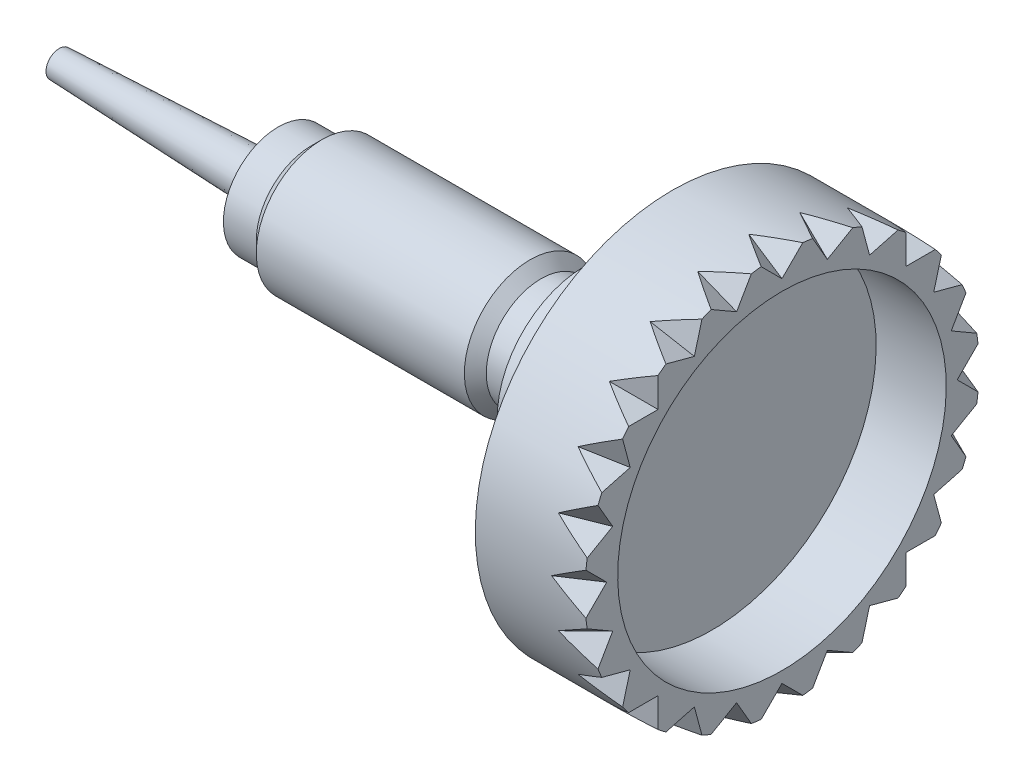
from build123d import *

# Parameters (mm, degrees)
CUT_EXTRUDE1_DEPTH = 1
CUT_EXTRUDE1_TAPER = 25
CIRPATTERN1_COUNT  = 24


with BuildPart() as part:
    # Sketch1 → Revolve1 (revolve)
    with BuildSketch(Plane.XY):
        Polygon((0, 0), (0, 0.3), (5, 0.5), (5, 1.25), (5.75, 1.25), (6, 1.5), (10.75, 1.5), (11, 1.25), (12, 1.25), (12, 2), (14, 2), (14, 4.5), (16.5, 4.5), (16.5, 3.75), (14.9, 3.75), (14.9, 0), align=None)
    revolve(axis=Axis((0, 0, 0), (-1, 0, 0)))

    # Sketch2 → Cut-Extrude1 (cut)
    with BuildSketch(Plane(origin=(16.5, 0, 0), x_dir=(0, 0, -1), z_dir=(1, 0, 0))):
        Polygon((0, 4), (1.25, 5.25), (-1.25, 5.25), align=None)
    cut_extrude1 = extrude(amount=-CUT_EXTRUDE1_DEPTH, taper=CUT_EXTRUDE1_TAPER, mode=Mode.SUBTRACT)

    # CirPattern1: Cut-Extrude1 ×24 about axis
    cirpattern1_axis = Axis((0, 0, 0), (1, 0, 0))
    for i in range(1, CIRPATTERN1_COUNT):
        add(cut_extrude1.rotate(cirpattern1_axis, i * 360 / CIRPATTERN1_COUNT), mode=Mode.SUBTRACT)


solid = part.part
